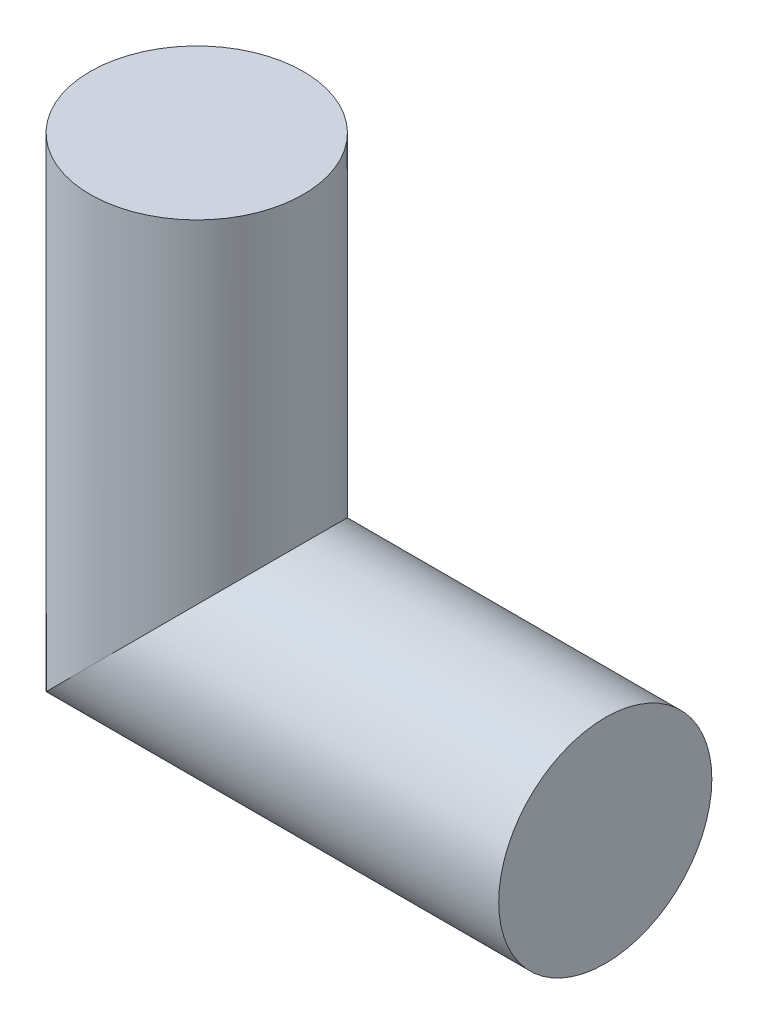
from build123d import *

# Parameters (mm, degrees)
SKETCH1_R = 6


with BuildPart() as part:
    # Sweep1: sweep along a path in Sketch2
    with BuildLine(Plane.XY) as sweep1_path:
        Line((0, 0), (-23, 0))
        Line((-23, 0), (-23, 23))
    # Sketch1 → Sweep1 (sweep)
    with BuildSketch(Plane(origin=(0, 0, 0), x_dir=(0, 0, -1), z_dir=(1, 0, 0))):
        Circle(SKETCH1_R)
    sweep(path=sweep1_path.line, transition=Transition.RIGHT)


solid = part.part
